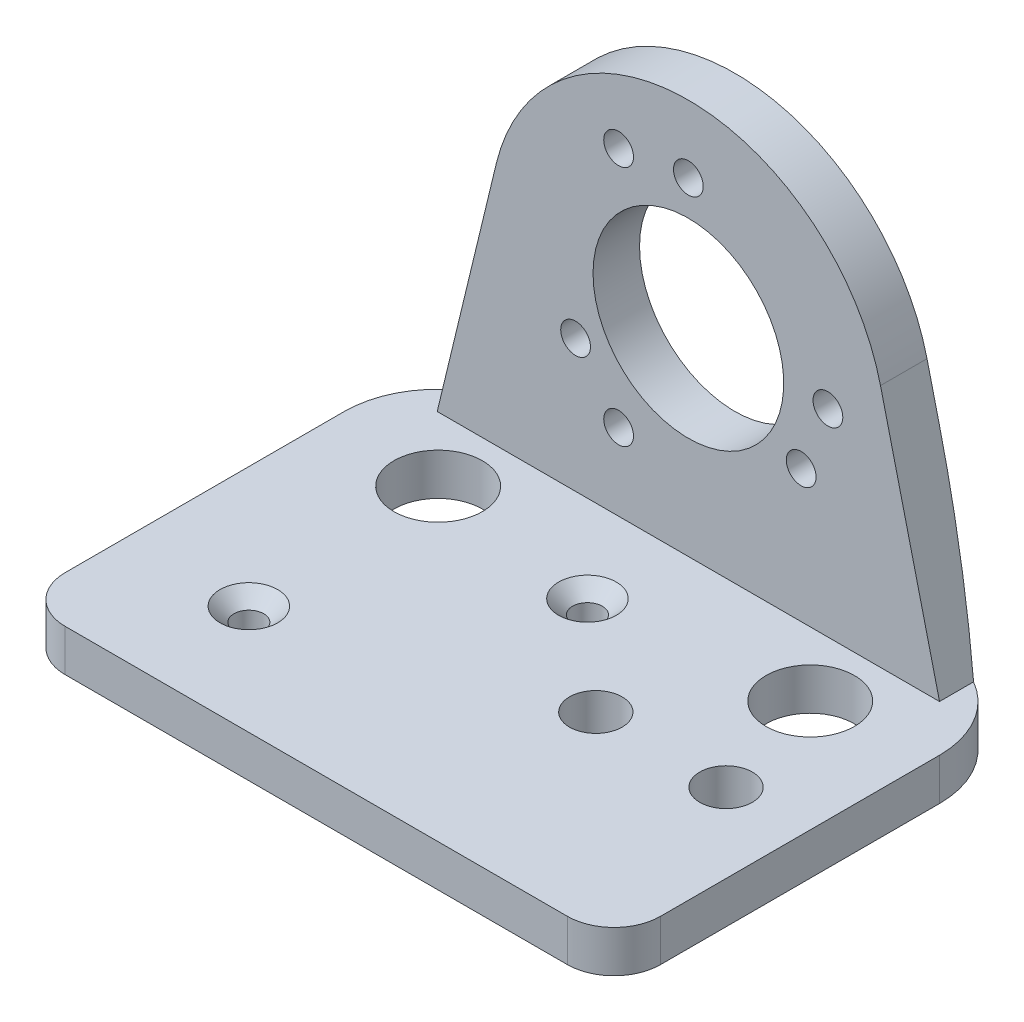
from build123d import *

# Parameters (mm, degrees)
SKETCH1_W           = 64
SKETCH1_H           = 45
SKETCH1_R           = 1.6
SKETCH1_R_2         = 2.825
SKETCH1_R_3         = 4.75
BOSS_EXTRUDE1_DEPTH = 4.5
CHAMFER1_SIZE       = 1.5
BOSS_EXTRUDE2_START = -22.5
SKETCH2_R           = 10.25
SKETCH2_R_2         = 1.6
BOSS_EXTRUDE2_DEPTH = 5
FILLET1_R           = 5
FILLET2_R           = 10


with BuildPart() as part:
    # Sketch1 → Boss-Extrude1 (new body)
    with BuildSketch(Plane(origin=(0, 0, 0), x_dir=(1, 0, 0), z_dir=(0, 1, 0))):
        Rectangle(SKETCH1_W, SKETCH1_H)
        with Locations((-1.5, 8.15)):
            Circle(SKETCH1_R, mode=Mode.SUBTRACT)
        with Locations((-19, -10.75)):
            Circle(SKETCH1_R, mode=Mode.SUBTRACT)
        with Locations((9.5, -1.95)):
            Circle(SKETCH1_R_2, mode=Mode.SUBTRACT)
        with Locations((23.5, -1.95)):
            Circle(SKETCH1_R_2, mode=Mode.SUBTRACT)
        with Locations((-20, 10.6)):
            Circle(SKETCH1_R_3, mode=Mode.SUBTRACT)
        with Locations((20, 10.6)):
            Circle(SKETCH1_R_3, mode=Mode.SUBTRACT)
    extrude(amount=-BOSS_EXTRUDE1_DEPTH)

    # Chamfer1
    chamfer1_edges = [part.edges().sort_by_distance(p)[0] for p in [
        (-3.1, 0, -8.15),
        (-20.6, 0, 10.75),
    ]]
    chamfer(chamfer1_edges, length=CHAMFER1_SIZE)

    # Sketch2 → Boss-Extrude2 (add)
    with BuildSketch(Plane.XY.offset(BOSS_EXTRUDE2_START)):
        with BuildLine():
            Line((-27, 0), (-20.654878501, 26.243845624))
            ThreePointArc((-20.654878501, 26.243845624), (0, 42.5), (20.654878501, 26.243845624))
            Line((20.654878501, 26.243845624), (27, 0))
            Line((27, 0), (27, -4.5))
            Line((27, -4.5), (-27, -4.5))
            Line((-27, -4.5), (-27, 0))
        make_face()
        with Locations((0, 21.25)):
            Circle(SKETCH2_R, mode=Mode.SUBTRACT)
        with Locations((0, 35.25)):
            Circle(SKETCH2_R_2, mode=Mode.SUBTRACT)
        with Locations((-7.5, 34.240381057)):
            Circle(SKETCH2_R_2, mode=Mode.SUBTRACT)
        with Locations((12.124355653, 14.25)):
            Circle(SKETCH2_R_2, mode=Mode.SUBTRACT)
        with Locations((15, 21.25)):
            Circle(SKETCH2_R_2, mode=Mode.SUBTRACT)
        with Locations((-12.124355653, 14.25)):
            Circle(SKETCH2_R_2, mode=Mode.SUBTRACT)
        with Locations((-7.5, 8.259618943)):
            Circle(SKETCH2_R_2, mode=Mode.SUBTRACT)
    extrude(amount=BOSS_EXTRUDE2_DEPTH)

    # Fillet1
    fillet1_edges = [part.edges().sort_by_distance(p)[0] for p in [
        (32, -2.25, 22.5),
        (-32, -2.25, 22.5),
    ]]
    fillet(fillet1_edges, radius=FILLET1_R)

    # Fillet2
    fillet2_edges = [part.edges().sort_by_distance(p)[0] for p in [
        (32, -2.25, -22.5),
        (-32, -2.25, -22.5),
    ]]
    fillet(fillet2_edges, radius=FILLET2_R)


solid = part.part
